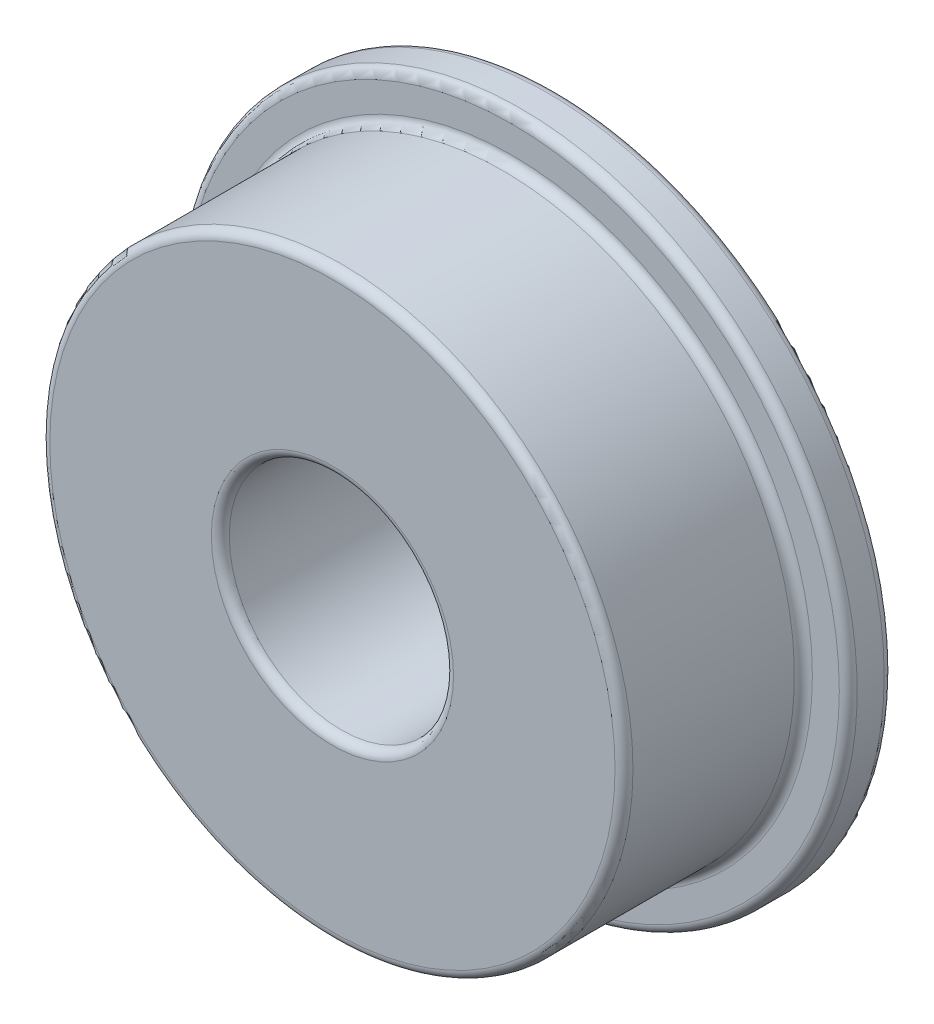
from build123d import *

# Parameters (mm, degrees)
SKETCH_1_R      = 6.5
SKETCH_1_R_2    = 2.5
EXTRUDE_1_DEPTH = 5
SKETCH_2_R      = 7.5
SKETCH_2_R_2    = 2.5
EXTRUDE_2_DEPTH = 1
FILLET_1_R      = 0.2


with BuildPart() as part:
    # 草图1 → 凸台-拉伸1 (new body)
    with BuildSketch(Plane.XY):
        Circle(SKETCH_1_R)
        Circle(SKETCH_1_R_2, mode=Mode.SUBTRACT)
    extrude(amount=EXTRUDE_1_DEPTH)

    # 草图2 → 凸台-拉伸2 (add)
    with BuildSketch(Plane(origin=(0, 0, 0), x_dir=(-1, 0, 0), z_dir=(0, 0, -1))):
        Circle(SKETCH_2_R)
        Circle(SKETCH_2_R_2, mode=Mode.SUBTRACT)
    extrude(amount=-EXTRUDE_2_DEPTH)

    # 圆角1
    fillet_1_edges = [part.edges().sort_by_distance(p)[0] for p in [
        (7.5, 0, 0),
        (7.5, 0, 1),
        (-6.5, 0, 5),
        (-2.5, 0, 0),
        (-2.5, 0, 5),
        (-6.5, 0, 1),
    ]]
    fillet(fillet_1_edges, radius=FILLET_1_R)


solid = part.part
